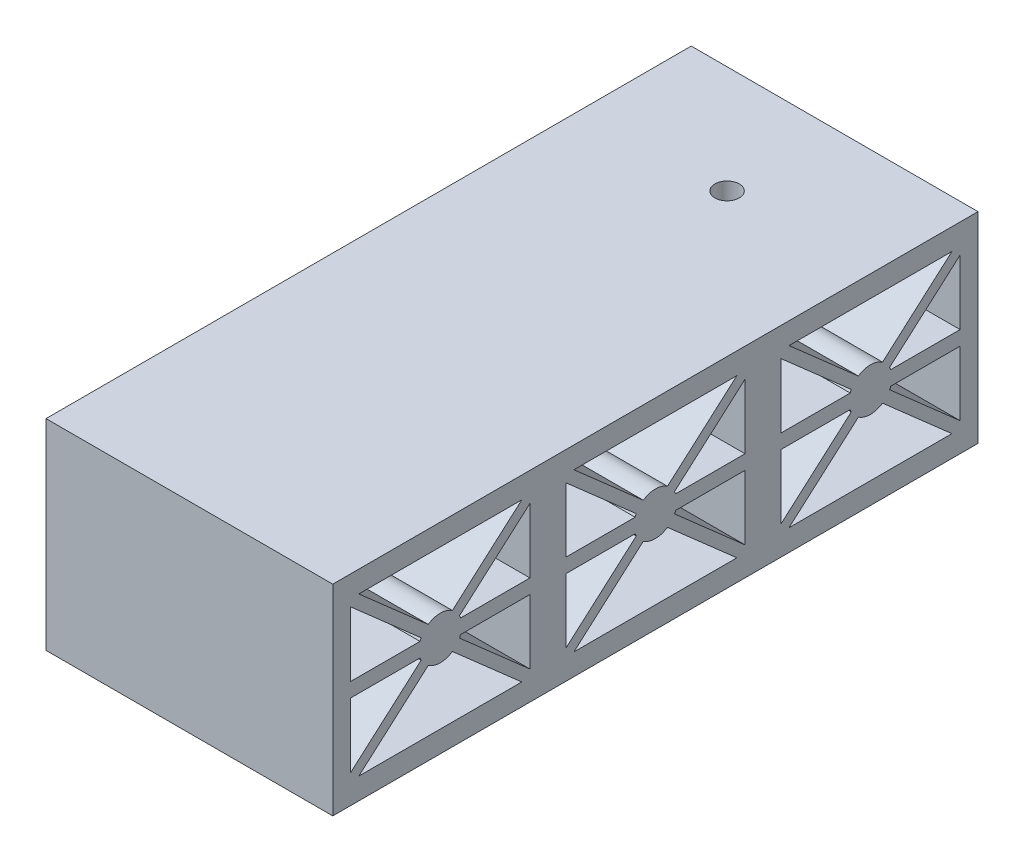
from build123d import *

# Parameters (mm, degrees)
SKETCH19_W          = 30
SKETCH19_H          = 28
SKETCH19_W_2        = 25
SKETCH19_H_2        = 22
BOSS_EXTRUDE1_DEPTH = 40
BOSS_EXTRUDE2_DEPTH = 40
LPATTERN2_COUNT     = 3
LPATTERN2_PITCH     = 30
SKETCH22_R          = 1.7
CUT_EXTRUDE1_DEPTH  = 29
CUT_EXTRUDE2_DEPTH  = 2.32


with BuildPart() as part:
    # Sketch19 → Boss-Extrude1 (new body)
    with BuildSketch(Plane(origin=(0, 0, 0), x_dir=(0, 0, -1), z_dir=(1, 0, 0))):
        with Locations((1, -10)):
            Rectangle(SKETCH19_W, SKETCH19_H)
        with Locations((1, -10)):
            Rectangle(SKETCH19_W_2, SKETCH19_H_2, mode=Mode.SUBTRACT)
    extrude(amount=-BOSS_EXTRUDE1_DEPTH)

    # Sketch21 → Boss-Extrude2 (add)
    with BuildSketch(Plane(origin=(0, 0, 0), x_dir=(0, 0, -1), z_dir=(1, 0, 0))):
        with BuildLine():
            Line((-11.995470921, 0.436964862), (-1.676096633, -8.644084511))
            ThreePointArc((-1.676096633, -8.644084511), (-1.252140551, -8.018116315), (-0.68515479, -7.518014236))
            Line((-0.68515479, -7.518014236), (-11.004529079, 1.563035138))
            Line((-11.004529079, 1.563035138), (-11.995470921, 0.436964862))
        make_face()
        with BuildLine():
            Line((13.004529079, 1.563035138), (2.68515479, -7.518014236))
            ThreePointArc((2.68515479, -7.518014236), (3.252140551, -8.018116315), (3.676096633, -8.644084511))
            Line((3.676096633, -8.644084511), (13.995470921, 0.436964862))
            Line((13.995470921, 0.436964862), (13.004529079, 1.563035138))
        make_face()
        with BuildLine():
            Line((-1.828427125, -9), (-11.5, -9))
            Line((-11.5, -9), (-11.5, -11))
            Line((-11.5, -11), (-1.828427125, -11))
            ThreePointArc((-1.828427125, -11), (-2, -10), (-1.828427125, -9))
        make_face()
        with BuildLine():
            Line((13.5, -9), (3.828427125, -9))
            ThreePointArc((3.828427125, -9), (3.956795679, -9.492694064), (4, -10))
            ThreePointArc((4, -10), (3.956795679, -10.507305936), (3.828427125, -11))
            Line((3.828427125, -11), (13.5, -11))
            Line((13.5, -11), (13.5, -9))
        make_face()
        with BuildLine():
            ThreePointArc((-0.68515479, -12.481985764), (-1.252140551, -11.981883685), (-1.676096633, -11.355915489))
            Line((-1.676096633, -11.355915489), (-11.995470921, -20.436964862))
            Line((-11.995470921, -20.436964862), (-11.004529079, -21.563035138))
            Line((-11.004529079, -21.563035138), (-0.68515479, -12.481985764))
        make_face()
        with BuildLine():
            ThreePointArc((3.676096633, -11.355915489), (3.252140551, -11.981883685), (2.68515479, -12.481985764))
            Line((2.68515479, -12.481985764), (13.004529079, -21.563035138))
            Line((13.004529079, -21.563035138), (13.995470921, -20.436964862))
            Line((13.995470921, -20.436964862), (3.676096633, -11.355915489))
        make_face()
        with BuildLine():
            Line((-1.271647214, -9), (-1.828427125, -9))
            ThreePointArc((-1.828427125, -9), (-2, -10), (-1.828427125, -11))
            Line((-1.828427125, -11), (-1.271647214, -11))
            Line((-1.271647214, -11), (-0.135283578, -10))
            Line((-0.135283578, -10), (-1.271647214, -9))
        make_face()
        with BuildLine():
            Line((3.828427125, -9), (3.271647214, -9))
            Line((3.271647214, -9), (2.135283578, -10))
            Line((2.135283578, -10), (3.271647214, -11))
            Line((3.271647214, -11), (3.828427125, -11))
            ThreePointArc((3.828427125, -11), (3.956795679, -10.507305936), (4, -10))
            ThreePointArc((4, -10), (3.956795679, -9.492694064), (3.828427125, -9))
        make_face()
        with BuildLine():
            ThreePointArc((-1.676096633, -8.644084511), (-1.758009138, -8.81958245), (-1.828427125, -9))
            Line((-1.828427125, -9), (-1.271647214, -9))
            Line((-1.271647214, -9), (-1.676096633, -8.644084511))
        make_face()
        with BuildLine():
            Line((-1.676096633, -8.644084511), (-1.271647214, -9))
            Line((-1.271647214, -9), (0.998919941, -9))
            Line((0.998919941, -9), (-0.68515479, -7.518014236))
            ThreePointArc((-0.68515479, -7.518014236), (-1.252140551, -8.018116315), (-1.676096633, -8.644084511))
        make_face()
        Polygon((0.998919941, -9), (-1.271647214, -9), (-0.135283578, -10), (1, -9.000950452), align=None)
        with BuildLine():
            Line((-1.271647214, -11), (-1.828427125, -11))
            ThreePointArc((-1.828427125, -11), (-1.758009138, -11.18041755), (-1.676096633, -11.355915489))
            Line((-1.676096633, -11.355915489), (-1.271647214, -11))
        make_face()
        with BuildLine():
            Line((-0.68515479, -7.518014236), (0.998919941, -9))
            Line((0.998919941, -9), (1.001080059, -9))
            Line((1.001080059, -9), (2.68515479, -7.518014236))
            ThreePointArc((2.68515479, -7.518014236), (1, -7), (-0.68515479, -7.518014236))
        make_face()
        Polygon((1.001080059, -9), (0.998919941, -9), (1, -9.000950452), align=None)
        Polygon((1, -10.999049548), (-0.135283578, -10), (-1.271647214, -11), (0.998919941, -11), align=None)
        Polygon((1, -9.000950452), (-0.135283578, -10), (1, -10.999049548), (2.135283578, -10), align=None)
        with BuildLine():
            Line((0.998919941, -11), (-1.271647214, -11))
            Line((-1.271647214, -11), (-1.676096633, -11.355915489))
            ThreePointArc((-1.676096633, -11.355915489), (-1.252140551, -11.981883685), (-0.68515479, -12.481985764))
            Line((-0.68515479, -12.481985764), (0.998919941, -11))
        make_face()
        with BuildLine():
            Line((2.68515479, -7.518014236), (1.001080059, -9))
            Line((1.001080059, -9), (3.271647214, -9))
            Line((3.271647214, -9), (3.676096633, -8.644084511))
            ThreePointArc((3.676096633, -8.644084511), (3.252140551, -8.018116315), (2.68515479, -7.518014236))
        make_face()
        Polygon((3.271647214, -9), (1.001080059, -9), (1, -9.000950452), (2.135283578, -10), align=None)
        Polygon((1.001080059, -11), (1, -10.999049548), (0.998919941, -11), align=None)
        Polygon((2.135283578, -10), (1, -10.999049548), (1.001080059, -11), (3.271647214, -11), align=None)
        with BuildLine():
            Line((1.001080059, -11), (0.998919941, -11))
            Line((0.998919941, -11), (-0.68515479, -12.481985764))
            ThreePointArc((-0.68515479, -12.481985764), (1, -13), (2.68515479, -12.481985764))
            Line((2.68515479, -12.481985764), (1.001080059, -11))
        make_face()
        with BuildLine():
            Line((3.676096633, -8.644084511), (3.271647214, -9))
            Line((3.271647214, -9), (3.828427125, -9))
            ThreePointArc((3.828427125, -9), (3.758009138, -8.81958245), (3.676096633, -8.644084511))
        make_face()
        with BuildLine():
            Line((3.271647214, -11), (1.001080059, -11))
            Line((1.001080059, -11), (2.68515479, -12.481985764))
            ThreePointArc((2.68515479, -12.481985764), (3.252140551, -11.981883685), (3.676096633, -11.355915489))
            Line((3.676096633, -11.355915489), (3.271647214, -11))
        make_face()
        with BuildLine():
            Line((3.828427125, -11), (3.271647214, -11))
            Line((3.271647214, -11), (3.676096633, -11.355915489))
            ThreePointArc((3.676096633, -11.355915489), (3.758009138, -11.18041755), (3.828427125, -11))
        make_face()
    extrude(amount=-BOSS_EXTRUDE2_DEPTH)


with BuildPart() as lpattern2_1:
    # LPattern2: pattern copy
    add(part.part.moved(Location(Vector(0, 0, 1) * (1 * LPATTERN2_PITCH))))


with BuildPart() as lpattern2_2:
    # LPattern2: pattern copy
    add(part.part.moved(Location(Vector(0, 0, 1) * (2 * LPATTERN2_PITCH))))


with BuildPart() as part_1:
    add(part.part)

    # Sketch22 → Cut-Extrude1 (cut, through all)
    with BuildSketch(Plane(origin=(0, 4, 0), x_dir=(1, 0, 0), z_dir=(0, 1, 0))):
        with Locations((-20, 1)):
            Circle(SKETCH22_R)
    extrude(amount=-CUT_EXTRUDE1_DEPTH, mode=Mode.SUBTRACT)

    # Sketch32 → Cut-Extrude2 (cut)
    with BuildSketch(Plane(origin=(0, -24, 0), x_dir=(-1, 0, 0), z_dir=(0, -1, 0))):
        Polygon((16.535898385, 1), (18.267949192, -2), (21.732050808, -2), (23.464101615, 1), (21.732050808, 4), (18.267949192, 4), align=None)
    extrude(amount=-CUT_EXTRUDE2_DEPTH, mode=Mode.SUBTRACT)

    # Combine1: union LPattern2_1, LPattern2_2
    add(lpattern2_1.part)
    add(lpattern2_2.part)


solid = part_1.part
